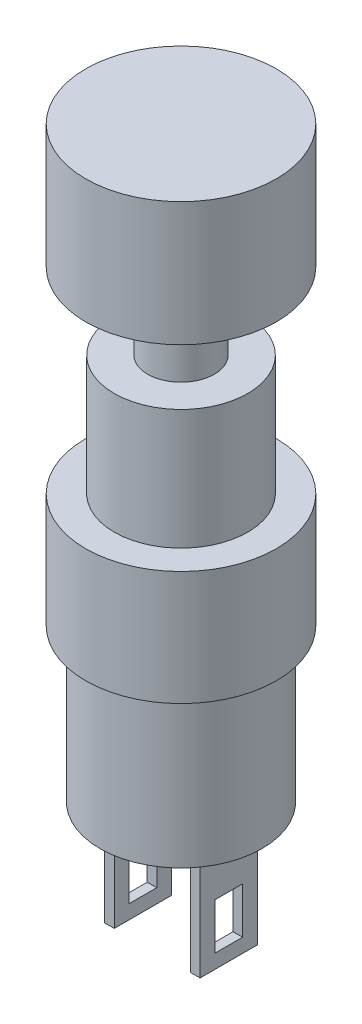
from build123d import *

# Parameters (mm, degrees)
ESBO_O1_R                = 5
RESSALTO_EXTRUS_O1_DEPTH = 6
ESBO_O2_R                = 4.25
RESSALTO_EXTRUS_O2_DEPTH = 8
ESBO_O3_W                = 0.5
ESBO_O3_H                = 3
RESSALTO_EXTRUS_O3_DEPTH = 6
ESBO_O4_W                = 1.442967266
ESBO_O4_H                = 2.423445024
CORTE_EXTRUS_O1_DEPTH    = 8.5
ESBO_O5_R                = 3.5
RESSALTO_EXTRUS_O4_DEPTH = 6.3
ESBO_O6_R                = 1.75
RESSALTO_EXTRUS_O5_DEPTH = 4
ESBO_O7_R                = 5
RESSALTO_EXTRUS_O6_DEPTH = 6.5


with BuildPart() as part:
    # Esboço1 → Ressalto-extrusão1 (new body)
    with BuildSketch(Plane(origin=(0, 0, 0), x_dir=(1, 0, 0), z_dir=(0, 1, 0))):
        Circle(ESBO_O1_R)
    extrude(amount=RESSALTO_EXTRUS_O1_DEPTH)

    # Esboço2 → Ressalto-extrusão2 (add)
    with BuildSketch(Plane.XZ):
        Circle(ESBO_O2_R)
    extrude(amount=RESSALTO_EXTRUS_O2_DEPTH)

    # Esboço3 → Ressalto-extrusão3 (add)
    with BuildSketch(Plane.XZ.offset(8)):
        with Locations((2.25, 0)):
            Rectangle(ESBO_O3_W, ESBO_O3_H)
        with Locations((-2.25, 0)):
            Rectangle(ESBO_O3_W, ESBO_O3_H)
    extrude(amount=RESSALTO_EXTRUS_O3_DEPTH)

    # Esboço4 → Corte-extrusão1 (cut, through all)
    with BuildSketch(Plane.ZY.offset(2.5)):
        with Locations((-0.007097641, -12.050464305)):
            Rectangle(ESBO_O4_W, ESBO_O4_H)
    extrude(amount=-CORTE_EXTRUS_O1_DEPTH, mode=Mode.SUBTRACT)

    # Esboço5 → Ressalto-extrusão4 (add)
    with BuildSketch(Plane(origin=(0, 6, 0), x_dir=(1, 0, 0), z_dir=(0, 1, 0))):
        Circle(ESBO_O5_R)
    extrude(amount=RESSALTO_EXTRUS_O4_DEPTH)

    # Esboço6 → Ressalto-extrusão5 (add)
    with BuildSketch(Plane(origin=(0, 12.3, 0), x_dir=(1, 0, 0), z_dir=(0, 1, 0))):
        Circle(ESBO_O6_R)
    extrude(amount=RESSALTO_EXTRUS_O5_DEPTH)

    # Esboço7 → Ressalto-extrusão6 (add)
    with BuildSketch(Plane(origin=(0, 16.3, 0), x_dir=(1, 0, 0), z_dir=(0, 1, 0))):
        Circle(ESBO_O7_R)
    extrude(amount=RESSALTO_EXTRUS_O6_DEPTH)


solid = part.part
